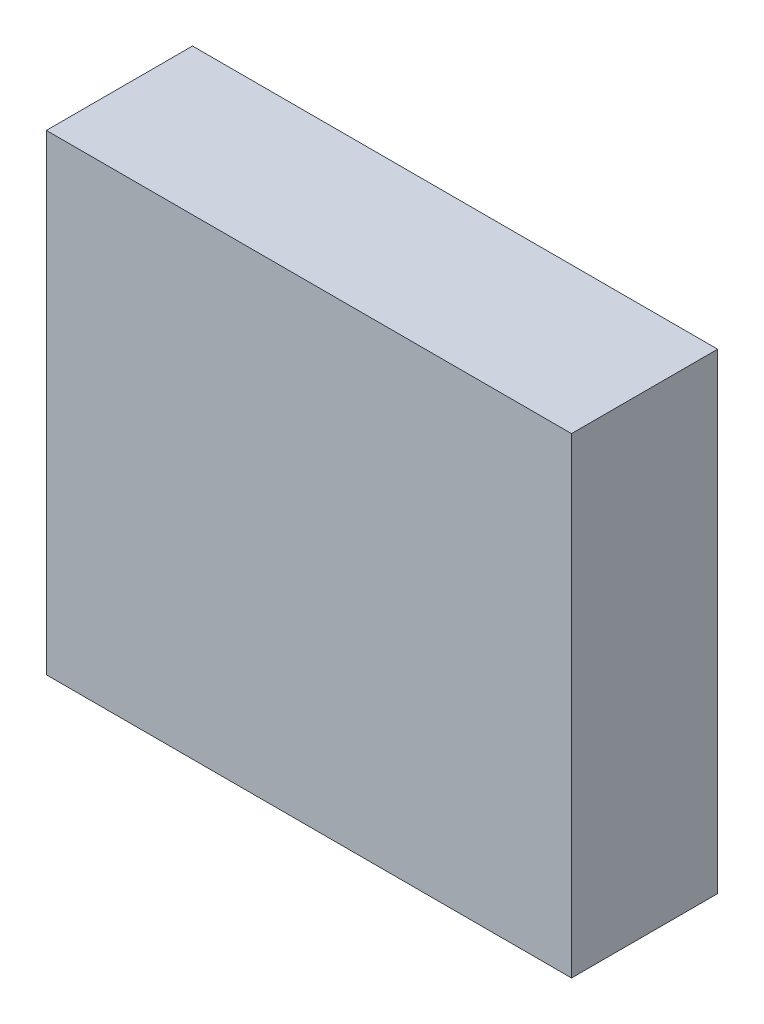
from build123d import *

# Parameters (mm, degrees)
SKETCH1_W           = 323.088
SKETCH1_H           = 89.916
BOSS_EXTRUDE1_DEPTH = 290.068
CUT_EXTRUDE1_START  = -5.08
SKETCH2_W           = 312.928
SKETCH2_H           = 79.756
CUT_EXTRUDE1_DEPTH  = 285.988


with BuildPart() as part:
    # Sketch1 → Boss-Extrude1 (new body)
    with BuildSketch(Plane(origin=(0, 0, 0), x_dir=(1, 0, 0), z_dir=(0, 1, 0))):
        with Locations((161.544, 44.958)):
            Rectangle(SKETCH1_W, SKETCH1_H)
    extrude(amount=BOSS_EXTRUDE1_DEPTH)

    # Sketch2 → Cut-Extrude1 (cut, through all)
    with BuildSketch(Plane(origin=(0, 290.068, 0), x_dir=(1, 0, 0), z_dir=(0, 1, 0)).offset(CUT_EXTRUDE1_START)):
        with Locations((161.544, 44.958)):
            Rectangle(SKETCH2_W, SKETCH2_H)
    extrude(amount=-CUT_EXTRUDE1_DEPTH, mode=Mode.SUBTRACT)


solid = part.part
